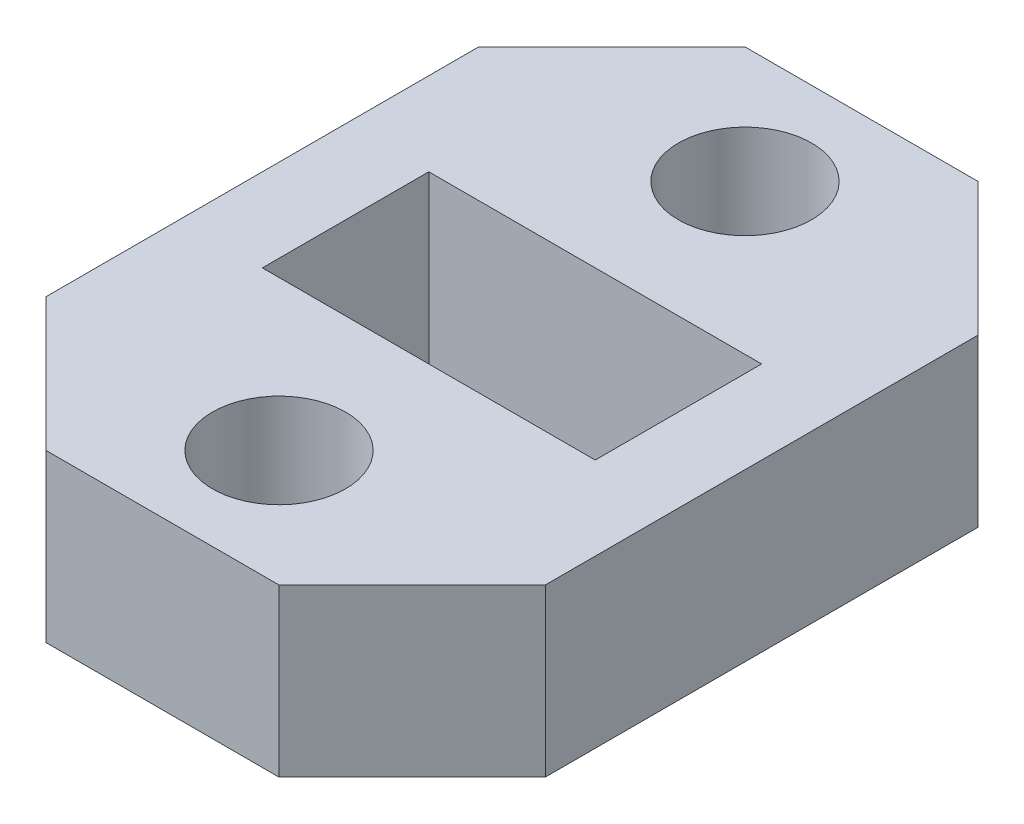
from build123d import *

# Parameters (mm, degrees)
SKETCH1_W           = 15
SKETCH1_H           = 21
BOSS_EXTRUDE1_DEPTH = 5
SKETCH2_R           = 2
SKETCH2_W           = 10
SKETCH2_H           = 5
CUT_EXTRUDE1_DEPTH  = 5
CHAMFER1_SIZE       = 4


with BuildPart() as part:
    # Sketch1 → Boss-Extrude1 (new body)
    with BuildSketch(Plane(origin=(0, 0, 0), x_dir=(1, 0, 0), z_dir=(0, 1, 0))):
        Rectangle(SKETCH1_W, SKETCH1_H)
    extrude(amount=BOSS_EXTRUDE1_DEPTH)

    # Sketch2 → Cut-Extrude1 (cut)
    with BuildSketch(Plane(origin=(0, 5, 0), x_dir=(1, 0, 0), z_dir=(0, 1, 0))):
        with Locations((0, 7)):
            Circle(SKETCH2_R)
        with Locations((0, -7)):
            Circle(SKETCH2_R)
        Rectangle(SKETCH2_W, SKETCH2_H)
    extrude(amount=-CUT_EXTRUDE1_DEPTH, mode=Mode.SUBTRACT)

    # Chamfer1
    chamfer1_edges = [part.edges().sort_by_distance(p)[0] for p in [
        (7.5, 2.5, 10.5),
        (-7.5, 2.5, 10.5),
        (-7.5, 2.5, -10.5),
        (7.5, 2.5, -10.5),
    ]]
    chamfer(chamfer1_edges, length=CHAMFER1_SIZE)


solid = part.part
